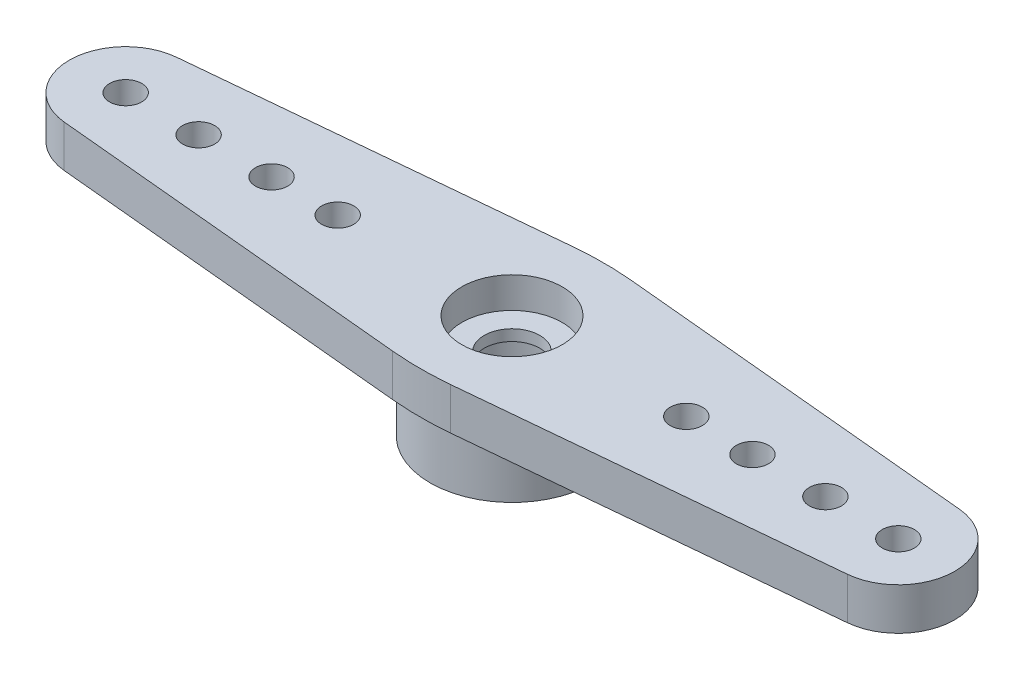
from build123d import *

# Parameters (mm, degrees)
SKETCH1_R           = 3.3655
SKETCH1_R_2         = 2.2352
BOSS_EXTRUDE1_DEPTH = 2.54
SKETCH2_R           = 0.6604
SKETCH2_R_2         = 2.31775
SKETCH2_R_3         = 3.3655
SKETCH2_R_4         = 2.2352
SKETCH2_R_5         = 1.143
BOSS_EXTRUDE2_DEPTH = 1.7272
FILLET1_R           = 12.7
SKETCH3_R           = 2.06375
SKETCH3_R_2         = 1.143
CUT_EXTRUDE1_DEPTH  = 1.27


with BuildPart() as part:
    # Sketch1 → Boss-Extrude1 (new body)
    with BuildSketch(Plane(origin=(0, 0, 0), x_dir=(1, 0, 0), z_dir=(0, 1, 0))):
        with Locations(Location((0, 0, 0), (0, 0, 270))):
            Circle(SKETCH1_R)
        with Locations(Location((0, 0, 0), (0, 0, 270))):
            Circle(SKETCH1_R_2, mode=Mode.SUBTRACT)
    extrude(amount=BOSS_EXTRUDE1_DEPTH)

    # Sketch2 → Boss-Extrude2 (add)
    with BuildSketch(Plane(origin=(0, 2.54, 0), x_dir=(1, 0, 0), z_dir=(0, 1, 0))):
        with BuildLine():
            ThreePointArc((-0.713521748, -3.755518873), (-3.8227, 0), (-0.713521748, 3.755518873))
            Line((-0.713521748, 3.755518873), (-16.092265178, 2.307544345))
            ThreePointArc((-16.092265178, 2.307544345), (-14.314807913, 1.713991165), (-13.55725, 0))
            ThreePointArc((-13.55725, 0), (-14.314807913, -1.713991165), (-16.092265178, -2.307544345))
            Line((-16.092265178, -2.307544345), (-0.713521748, -3.755518873))
        make_face()
        with Locations(Location((-12.8778, 0, 0), (0, 0, 270))):
            Circle(SKETCH2_R, mode=Mode.SUBTRACT)
        with Locations(Location((-9.8806, 0, 0), (0, 0, 270))):
            Circle(SKETCH2_R, mode=Mode.SUBTRACT)
        with Locations(Location((-7.1628, 0, 0), (0, 0, 270))):
            Circle(SKETCH2_R, mode=Mode.SUBTRACT)
        with Locations((-15.875, 0)):
            Circle(SKETCH2_R_2)
        with Locations(Location((-15.875, 0, 0), (0, 0, 270))):
            Circle(SKETCH2_R, mode=Mode.SUBTRACT)
        with BuildLine():
            Line((16.092265178, 2.307544345), (0.713521748, 3.755518873))
            ThreePointArc((0.713521748, 3.755518873), (2.944538578, 2.437771083), (3.8227, 0))
            ThreePointArc((3.8227, 0), (2.944538578, -2.437771083), (0.713521748, -3.755518873))
            Line((0.713521748, -3.755518873), (16.092265178, -2.307544345))
            ThreePointArc((16.092265178, -2.307544345), (13.55725, 0), (16.092265178, 2.307544345))
        make_face()
        with Locations(Location((7.1628, 0, 0), (0, 0, 270))):
            Circle(SKETCH2_R, mode=Mode.SUBTRACT)
        with Locations(Location((9.8806, 0, 0), (0, 0, 270))):
            Circle(SKETCH2_R, mode=Mode.SUBTRACT)
        with Locations(Location((12.8778, 0, 0), (0, 0, 270))):
            Circle(SKETCH2_R, mode=Mode.SUBTRACT)
        with Locations((15.875, 0)):
            Circle(SKETCH2_R_2)
        with Locations(Location((15.875, 0, 0), (0, 0, 270))):
            Circle(SKETCH2_R, mode=Mode.SUBTRACT)
        with BuildLine():
            Line((0.713521748, 3.755518873), (0, 3.8227))
            Line((0, 3.8227), (-0.713521748, 3.755518873))
            ThreePointArc((-0.713521748, 3.755518873), (-3.8227, 0), (-0.713521748, -3.755518873))
            Line((-0.713521748, -3.755518873), (0, -3.8227))
            Line((0, -3.8227), (0.713521748, -3.755518873))
            ThreePointArc((0.713521748, -3.755518873), (2.944538578, -2.437771083), (3.8227, 0))
            ThreePointArc((3.8227, 0), (2.944538578, 2.437771083), (0.713521748, 3.755518873))
        make_face()
        with Locations(Location((0, 0, 0), (0, 0, 270))):
            Circle(SKETCH2_R_3, mode=Mode.SUBTRACT)
        with Locations(Location((0, 0, 0), (0, 0, 270))):
            Circle(SKETCH2_R_3)
        with Locations(Location((0, 0, 0), (0, 0, 270))):
            Circle(SKETCH2_R_4, mode=Mode.SUBTRACT)
        with Locations(Location((0, 0, 0), (0, 0, 270))):
            Circle(SKETCH2_R_4)
        with Locations(Location((0, 0, 0), (0, 0, 270))):
            Circle(SKETCH2_R_5, mode=Mode.SUBTRACT)
    extrude(amount=BOSS_EXTRUDE2_DEPTH)

    # Fillet1
    fillet1_edges = [part.edges().sort_by_distance(p)[0] for p in [
        (0, 3.4036, -3.8227),
        (0, 3.4036, 3.8227),
    ]]
    fillet(fillet1_edges, radius=FILLET1_R)

    # Sketch3 → Cut-Extrude1 (cut)
    with BuildSketch(Plane(origin=(0, 4.2672, 0), x_dir=(1, 0, 0), z_dir=(0, 1, 0))):
        with Locations(Location((0, 0, 0), (0, 0, 270))):
            Circle(SKETCH3_R)
        with Locations(Location((0, 0, 0), (0, 0, 270))):
            Circle(SKETCH3_R_2, mode=Mode.SUBTRACT)
    extrude(amount=-CUT_EXTRUDE1_DEPTH, mode=Mode.SUBTRACT)


solid = part.part
